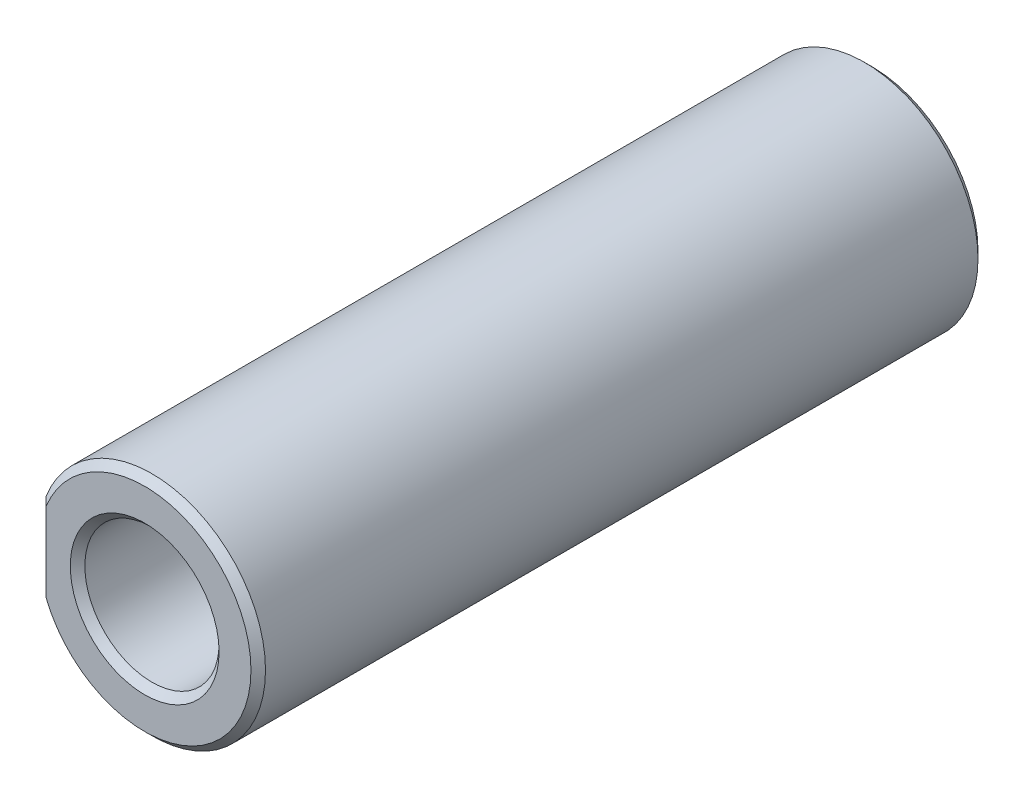
from build123d import *

# Parameters (mm, degrees)
SKETCH1_R                    = 5.95
BOSS_EXTRUDE1_DEPTH          = 38.1
SKETCH2_R                    = 3.175
BOSS_EXTRUDE2_DEPTH          = 1.5875
J_0_277_DIAMETER_HOLE1_D     = 7.0358
J_0_277_DIAMETER_HOLE1_DEPTH = 28.575
J_0_277_DIAMETER_HOLE1_TIP   = 2.113767572
F_8_32_TAPPED_HOLE2_D        = 3.4544
SKETCH9_W                    = 38.1
SKETCH9_H                    = 6
CUT_EXTRUDE3_DEPTH           = 1.396875
CHAMFER1_SIZE                = 0.381
FILLET1_R                    = 0.396875


with BuildPart() as part:
    # Sketch1 → Boss-Extrude1 (new body)
    with BuildSketch(Plane.XY):
        Circle(SKETCH1_R)
    extrude(amount=BOSS_EXTRUDE1_DEPTH)

    # Sketch2 → Boss-Extrude2 (add)
    with BuildSketch(Plane(origin=(0, 0, 0), x_dir=(-1, 0, 0), z_dir=(0, 0, -1))):
        Circle(SKETCH2_R)
    extrude(amount=BOSS_EXTRUDE2_DEPTH)

    # J (0.277) Diameter Hole1
    with Locations(Plane.XY.offset(38.1)):
        with Locations((0, 0)):
            Hole(J_0_277_DIAMETER_HOLE1_D / 2, depth=J_0_277_DIAMETER_HOLE1_DEPTH)
            with Locations((0, 0, -(J_0_277_DIAMETER_HOLE1_DEPTH + J_0_277_DIAMETER_HOLE1_TIP / 2))):  # 118° drill point
                Cone(0, J_0_277_DIAMETER_HOLE1_D / 2, J_0_277_DIAMETER_HOLE1_TIP, mode=Mode.SUBTRACT)

    # #8-32 Tapped Hole2 (through all)
    with Locations(Plane(origin=(0, 0, -1.5875), x_dir=(-1, 0, 0), z_dir=(0, 0, -1))):
        with Locations((0, 0)):
            Hole(F_8_32_TAPPED_HOLE2_D / 2)

    # Sketch9 → Cut-Extrude3 (cut, through all)
    with BuildSketch(Plane.ZY.offset(5.553125)):
        with Locations((19.05, 0)):
            Rectangle(SKETCH9_W, SKETCH9_H)
    extrude(amount=CUT_EXTRUDE3_DEPTH, mode=Mode.SUBTRACT)

    # Chamfer1
    chamfer1_edges = [part.edges().sort_by_distance(p)[0] for p in [
        (3.5179, 0, 38.1),
        (-1.7272, 0, -1.5875),
        (5.95, 0, 0),
        (-5.553125, 0, 0),
        (5.95, 0, 38.1),
        (-5.553125, 0, 38.1),
        (3.175, 0, -1.5875),
    ]]
    chamfer(chamfer1_edges, length=CHAMFER1_SIZE)

    # Fillet1
    fillet1_edges = [part.edges().sort_by_distance(p)[0] for p in [
        (3.175, 0, 0),
    ]]
    fillet(fillet1_edges, radius=FILLET1_R)


solid = part.part
